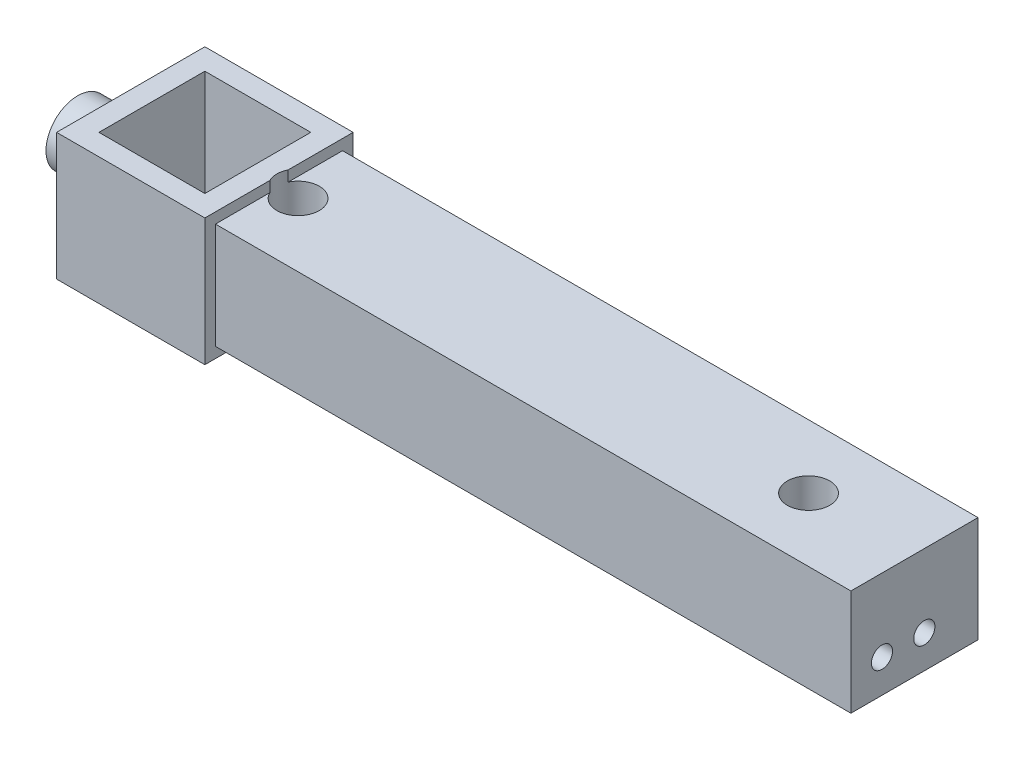
from build123d import *

# Parameters (mm, degrees)
SKETCH1_W               = 70
SKETCH1_H               = 70
SKETCH1_W_2             = 50
SKETCH1_H_2             = 50
BOSS_EXTRUDE1_DEPTH     = 60
SKETCH2_W               = 60
SKETCH2_H               = 50
BOSS_EXTRUDE2_DEPTH     = 300
SKETCH3_R               = 15
BOSS_EXTRUDE3_DEPTH     = 25
SKETCH4_R               = 10
CUT_EXTRUDE1_DEPTH      = 56
SKETCH5_R               = 10
CUT_EXTRUDE2_DEPTH      = 6
CUT_EXTRUDE2_DEPTH_BACK = 56
CUT_EXTRUDE3_START      = -20
SKETCH8_R               = 2.5
CUT_EXTRUDE3_DEPTH      = 30
SKETCH9_R               = 5
CUT_EXTRUDE4_DEPTH      = 17


with BuildPart() as part:
    # Sketch1 → Boss-Extrude1 (new body)
    with BuildSketch(Plane(origin=(0, 0, 0), x_dir=(1, 0, 0), z_dir=(0, 1, 0))):
        Rectangle(SKETCH1_W, SKETCH1_H)
        Rectangle(SKETCH1_W_2, SKETCH1_H_2, mode=Mode.SUBTRACT)
    extrude(amount=BOSS_EXTRUDE1_DEPTH)

    # Sketch2 → Boss-Extrude2 (add)
    with BuildSketch(Plane(origin=(35, 0, 0), x_dir=(0, 0, -1), z_dir=(1, 0, 0))):
        with Locations((0, 30)):
            Rectangle(SKETCH2_W, SKETCH2_H)
    extrude(amount=BOSS_EXTRUDE2_DEPTH)

    # Sketch3 → Boss-Extrude3 (add)
    with BuildSketch(Plane.ZY.offset(35)):
        with Locations((0, 30)):
            Circle(SKETCH3_R)
    extrude(amount=BOSS_EXTRUDE3_DEPTH)

    # Sketch4 → Cut-Extrude1 (cut, through all)
    with BuildSketch(Plane(origin=(0, 55, 0), x_dir=(1, 0, 0), z_dir=(0, 1, 0))):
        with Locations((285, 0)):
            Circle(SKETCH4_R)
    extrude(amount=-CUT_EXTRUDE1_DEPTH, mode=Mode.SUBTRACT)

    # Sketch5 → Cut-Extrude2 (cut, two sides)
    with BuildSketch(Plane(origin=(0, 55, 0), x_dir=(1, 0, 0), z_dir=(0, 1, 0))) as cut_extrude2_sk:
        with Locations((44, 0)):
            Circle(SKETCH5_R)
    extrude(amount=CUT_EXTRUDE2_DEPTH, mode=Mode.SUBTRACT)
    extrude(cut_extrude2_sk.sketch, amount=-CUT_EXTRUDE2_DEPTH_BACK, mode=Mode.SUBTRACT)

    # Sketch8 → Cut-Extrude3 (cut)
    with BuildSketch(Plane(origin=(0, 55, 0), x_dir=(1, 0, 0), z_dir=(0, 1, 0)).offset(CUT_EXTRUDE3_START)):
        with Locations((255.00002319, -0.037301815)):
            Circle(SKETCH8_R)
        with Locations((299.967684086, 25.999392937)):
            Circle(SKETCH8_R)
        with Locations((300.032292724, -25.962091123)):
            Circle(SKETCH8_R)
    extrude(amount=-CUT_EXTRUDE3_DEPTH, mode=Mode.SUBTRACT)

    # Sketch9 → Cut-Extrude4 (cut)
    with BuildSketch(Plane(origin=(335, 0, 0), x_dir=(0, 0, -1), z_dir=(1, 0, 0))):
        with Locations((-15.340483078, 20.605088766)):
            Circle(SKETCH9_R)
        with Locations((4.659516922, 20.605088766)):
            Circle(SKETCH9_R)
    extrude(amount=-CUT_EXTRUDE4_DEPTH, mode=Mode.SUBTRACT)


solid = part.part
